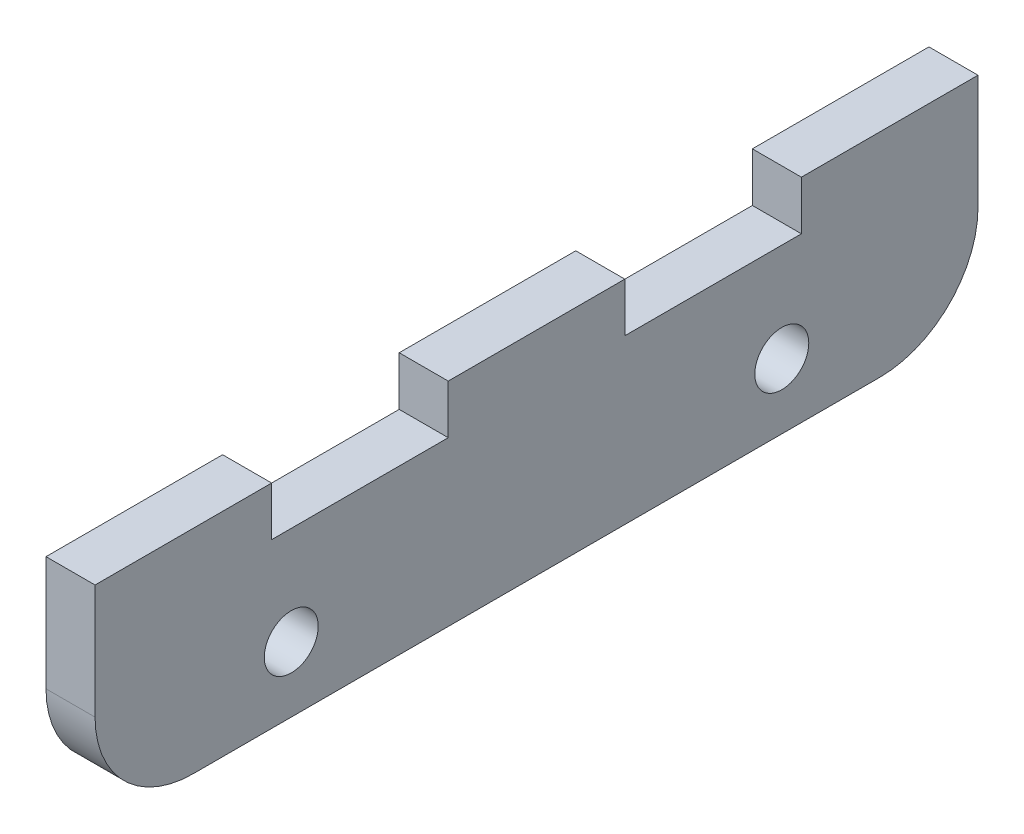
from build123d import *

# Parameters (mm, degrees)
SKETCH1_R           = 1.65
BOSS_EXTRUDE1_DEPTH = 3


with BuildPart() as part:
    # Sketch1 → Boss-Extrude1 (new body)
    with BuildSketch(Plane(origin=(0, 0, 0), x_dir=(0, 0, -1), z_dir=(1, 0, 0))):
        with BuildLine():
            Line((21, -6.5), (-21, -6.5))
            ThreePointArc((-21, -6.5), (-25.242640687, -4.742640687), (-27, -0.5))
            Line((-27, -0.5), (-27, 6.5))
            Line((-27, 6.5), (-16.2, 6.5))
            Line((-16.2, 6.5), (-16.2, 3.5))
            Line((-16.2, 3.5), (-5.4, 3.5))
            Line((-5.4, 3.5), (-5.4, 6.5))
            Line((-5.4, 6.5), (5.4, 6.5))
            Line((5.4, 6.5), (5.4, 3.5))
            Line((5.4, 3.5), (16.2, 3.5))
            Line((16.2, 3.5), (16.2, 6.5))
            Line((16.2, 6.5), (27, 6.5))
            Line((27, 6.5), (27, -0.5))
            ThreePointArc((27, -0.5), (25.242640687, -4.742640687), (21, -6.5))
        make_face()
        with Locations((-15, -2.509032308)):
            Circle(SKETCH1_R, mode=Mode.SUBTRACT)
        with Locations((15, -2.509032308)):
            Circle(SKETCH1_R, mode=Mode.SUBTRACT)
    extrude(amount=BOSS_EXTRUDE1_DEPTH)


solid = part.part
